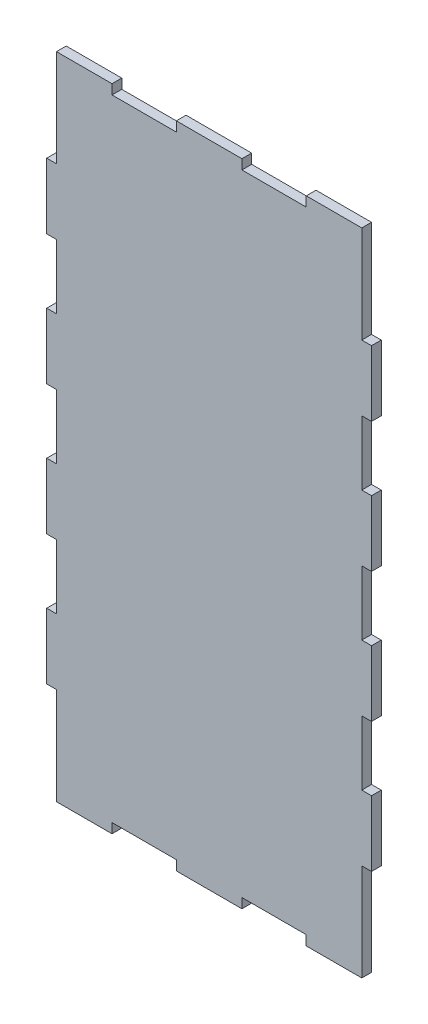
from build123d import *

# Parameters (mm, degrees)
BOSS_EXTRUDE1_DEPTH = 3


with BuildPart() as part:
    # Sketch1 → Boss-Extrude1 (new body)
    with BuildSketch(Plane.XY):
        Polygon((97, 109.9), (100, 109.9), (100, 130.1), (97, 130.1), (97, 149.9), (100, 149.9), (100, 170.1), (97, 170.1), (97, 200), (79.9, 200), (79.9, 197), (60.1, 197), (60.1, 200), (39.9, 200), (39.9, 197), (20.1, 197), (20.1, 200), (3, 200), (3, 170.1), (0, 170.1), (0, 149.9), (3, 149.9), (3, 130.1), (0, 130.1), (0, 109.9), (3, 109.9), (3, 90.1), (0, 90.1), (0, 69.9), (3, 69.9), (3, 50.1), (0, 50.1), (0, 29.9), (3, 29.9), (3, 0), (20.1, 0), (20.1, 3), (39.9, 3), (39.9, 0), (60.1, 0), (60.1, 3), (79.9, 3), (79.9, 0), (97, 0), (97, 29.9), (100, 29.9), (100, 50.1), (97, 50.1), (97, 69.9), (100, 69.9), (100, 90.1), (97, 90.1), align=None)
    extrude(amount=BOSS_EXTRUDE1_DEPTH)


solid = part.part
